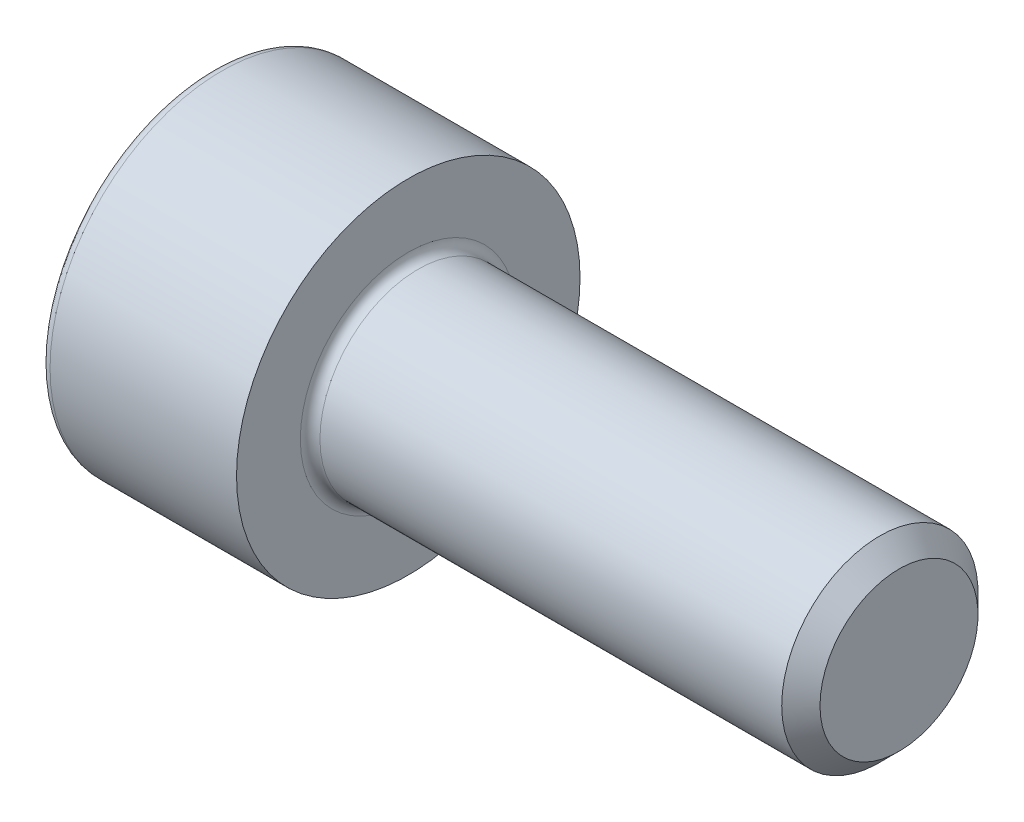
from build123d import *

# Parameters (mm, degrees)
FILLET1_R   = 0.2
FILLET2_R   = 0.2
HEX_2_DEPTH = 2


with BuildPart() as part:
    # BodySke → BaseBody (revolve)
    with BuildSketch(Plane.XY):
        Polygon((0, 0), (0, 3.5), (4, 3.5), (4, 2), (13.61, 2), (14, 1.61), (14, 0), align=None)
    revolve(axis=Axis((0, 0, 0), (1, 0, 0)))

    # Fillet1
    fillet1_edges = [part.edges().sort_by_distance(p)[0] for p in [
        (4, -2, 0),
    ]]
    fillet(fillet1_edges, radius=FILLET1_R)

    # Fillet2
    fillet2_edges = [part.edges().sort_by_distance(p)[0] for p in [
        (0, -3.5, 0),
    ]]
    fillet(fillet2_edges, radius=FILLET2_R)

    # HexSke → Hex 2 (cut)
    with BuildSketch(Plane(origin=(0, 0, 0), x_dir=(0, 0, -1), z_dir=(1, 0, 0))):
        Polygon((0, 1.732050808), (-1.5, 0.866025404), (-1.5, -0.866025404), (0, -1.732050808), (1.5, -0.866025404), (1.5, 0.866025404), align=None)
    extrude(amount=HEX_2_DEPTH, mode=Mode.SUBTRACT)

    # Hex-PreBroachSke → Hex-PreBroach (revolve, cut)
    with BuildSketch(Plane.XY):
        Polygon((0, 0), (0, 1.5), (2, 1.5), (2.866025404, 0), align=None)
    revolve(axis=Axis((0, 0, 0), (1, 0, 0)), mode=Mode.SUBTRACT)


solid = part.part
